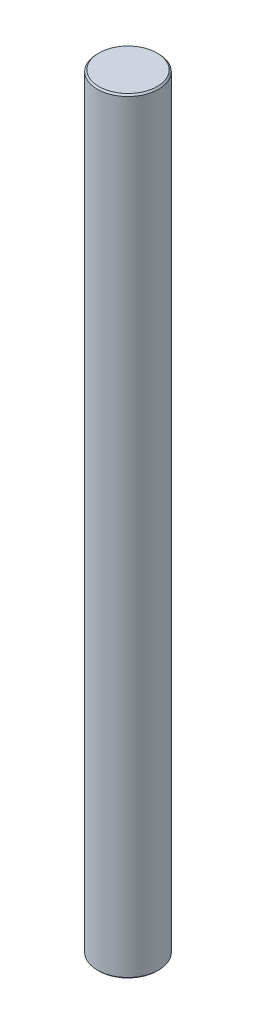
from build123d import *

# Parameters (mm, degrees)
SKETCH1_R           = 4
BOSS_EXTRUDE1_DEPTH = 100
CHAMFER1_SIZE       = 0.2


with BuildPart() as part:
    # Sketch1 → Boss-Extrude1 (new body)
    with BuildSketch(Plane(origin=(0, 0, 0), x_dir=(1, 0, 0), z_dir=(0, 1, 0))):
        Circle(SKETCH1_R)
    extrude(amount=BOSS_EXTRUDE1_DEPTH)

    # Chamfer1
    chamfer1_edges = [part.edges().sort_by_distance(p)[0] for p in [
        (-4, 0, 0),
        (-4, 100, 0),
    ]]
    chamfer(chamfer1_edges, length=CHAMFER1_SIZE)


solid = part.part
